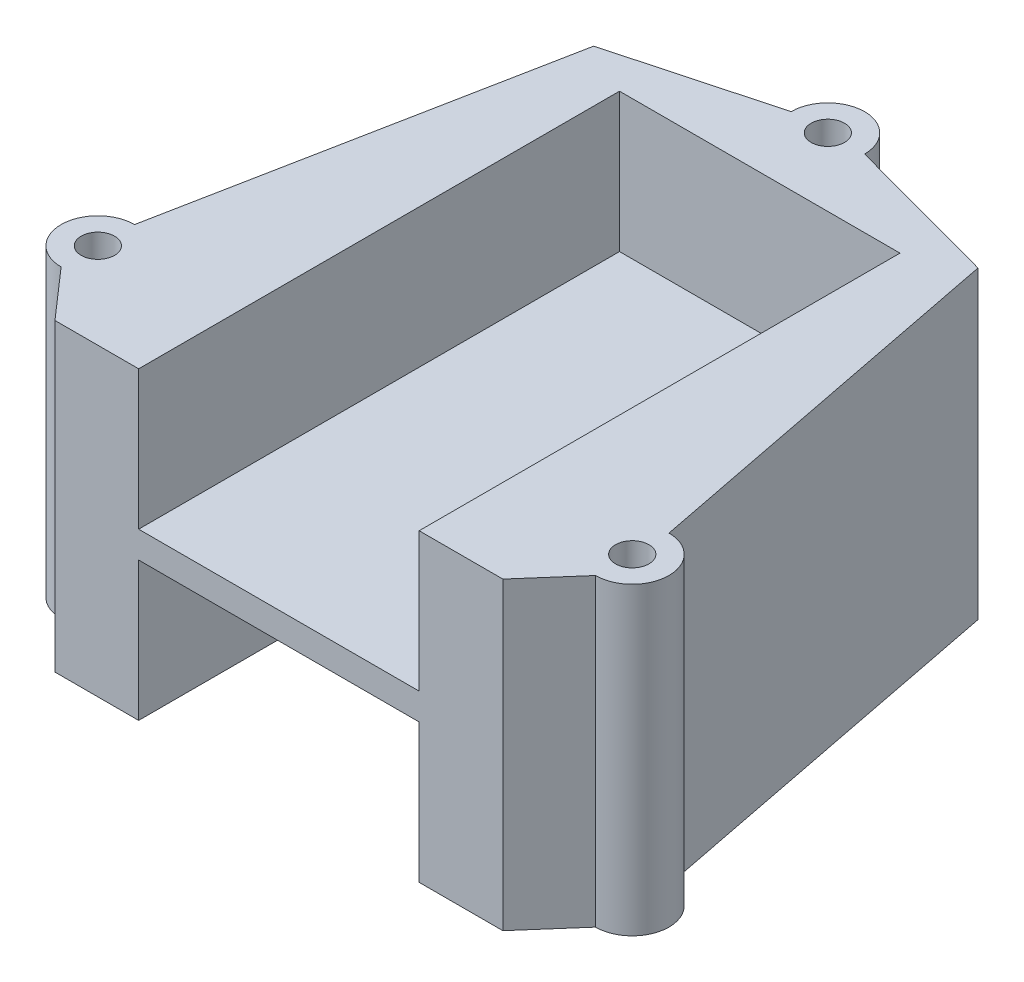
from build123d import *

# Parameters (mm, degrees)
SKETCH1_R           = 38.1
SKETCH1_R_2         = 1.5875
BOSS_EXTRUDE1_DEPTH = 2.54
SKETCH2_R           = 1.5875
BOSS_EXTRUDE2_DEPTH = 28.956
SKETCH3_W           = 26.67
SKETCH3_H           = 17.78
CUT_EXTRUDE1_DEPTH  = 45.72


with BuildPart() as part:
    # Sketch1 → Boss-Extrude1 (new body)
    with BuildSketch(Plane(origin=(0, 0, 0), x_dir=(1, 0, 0), z_dir=(0, 1, 0))):
        with Locations(Location((0, 0, 0), (0, 0, 270))):
            Circle(SKETCH1_R)
        with Locations(Location((0, 29.337, 0), (0, 0, 270))):
            Circle(SKETCH1_R_2, mode=Mode.SUBTRACT)
        with Locations(Location((25.406587271, -14.6685, 0), (0, 0, 270))):
            Circle(SKETCH1_R_2, mode=Mode.SUBTRACT)
        with Locations(Location((-25.406587271, -14.6685, 0), (0, 0, 270))):
            Circle(SKETCH1_R_2, mode=Mode.SUBTRACT)
    extrude(amount=BOSS_EXTRUDE1_DEPTH)


with BuildPart() as body_2:
    # Sketch2 → Boss-Extrude2 (new body)
    with BuildSketch(Plane(origin=(0, 2.54, 0), x_dir=(1, 0, 0), z_dir=(0, 1, 0))):
        with BuildLine():
            Line((25.406587271, -11.176), (18.270749664, 25.342499299))
            Line((18.270749664, 25.342499299), (3.4925, 29.337))
            ThreePointArc((3.4925, 29.337), (0, 32.8295), (-3.4925, 29.337))
            Line((-3.4925, 29.337), (-18.270749664, 25.342499299))
            Line((-18.270749664, 25.342499299), (-25.406587271, -11.176))
            ThreePointArc((-25.406587271, -11.176), (-28.899087271, -14.6685), (-25.406587271, -18.161))
            Line((-25.406587271, -18.161), (-21.295139445, -22.86))
            Line((-21.295139445, -22.86), (21.295139445, -22.86))
            Line((21.295139445, -22.86), (25.406587271, -18.161))
            ThreePointArc((25.406587271, -18.161), (28.899087271, -14.6685), (25.406587271, -11.176))
        make_face()
        with Locations(Location((25.406587271, -14.6685, 0), (0, 0, 270))):
            Circle(SKETCH2_R, mode=Mode.SUBTRACT)
        with Locations(Location((0, 29.337, 0), (0, 0, 270))):
            Circle(SKETCH2_R, mode=Mode.SUBTRACT)
        with Locations(Location((-25.406587271, -14.6685, 0), (0, 0, 270))):
            Circle(SKETCH2_R, mode=Mode.SUBTRACT)
    extrude(amount=BOSS_EXTRUDE2_DEPTH)

    # Sketch3 → Cut-Extrude1 (cut)
    with BuildSketch(Plane.XY.offset(22.86)):
        with Locations((0, 27.178)):
            Rectangle(SKETCH3_W, SKETCH3_H)
        with Locations((0, 6.858)):
            Rectangle(SKETCH3_W, SKETCH3_H)
    extrude(amount=-CUT_EXTRUDE1_DEPTH, mode=Mode.SUBTRACT)


solid = body_2.part
